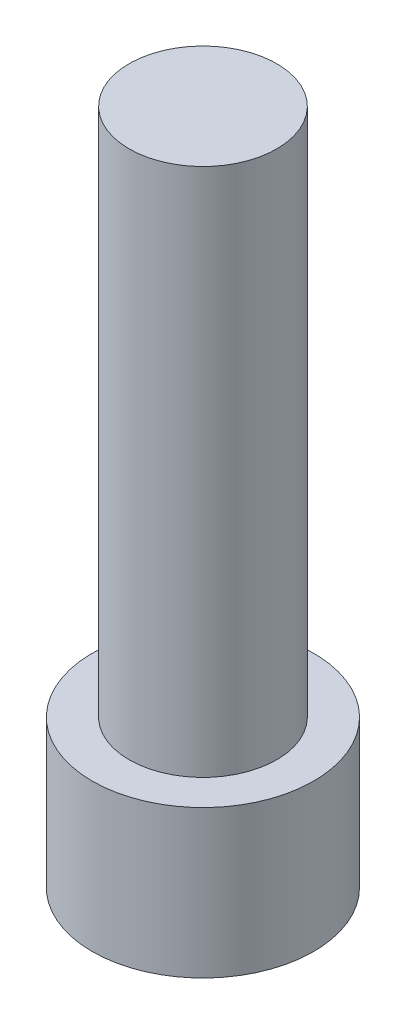
from build123d import *

# Parameters (mm, degrees)
CROQUIS1_R              = 4.5
SALIENTE_EXTRUIR1_DEPTH = 6
CROQUIS2_R              = 3
SALIENTE_EXTRUIR2_DEPTH = 21.5
CORTAR_EXTRUIR1_DEPTH   = 5


with BuildPart() as part:
    # Croquis1 → Saliente-Extruir1 (new body)
    with BuildSketch(Plane(origin=(0, 0, 0), x_dir=(1, 0, 0), z_dir=(0, 1, 0))):
        Circle(CROQUIS1_R)
    extrude(amount=SALIENTE_EXTRUIR1_DEPTH)

    # Croquis2 → Saliente-Extruir2 (add)
    with BuildSketch(Plane(origin=(0, 6, 0), x_dir=(1, 0, 0), z_dir=(0, 1, 0))):
        Circle(CROQUIS2_R)
    extrude(amount=SALIENTE_EXTRUIR2_DEPTH)

    # Croquis3 → Cortar-Extruir1 (cut)
    with BuildSketch(Plane.XZ):
        Polygon((2.886751346, 0), (1.443375673, 2.5), (-1.443375673, 2.5), (-2.886751346, 0), (-1.443375673, -2.5), (1.443375673, -2.5), align=None)
    extrude(amount=-CORTAR_EXTRUIR1_DEPTH, mode=Mode.SUBTRACT)


solid = part.part
